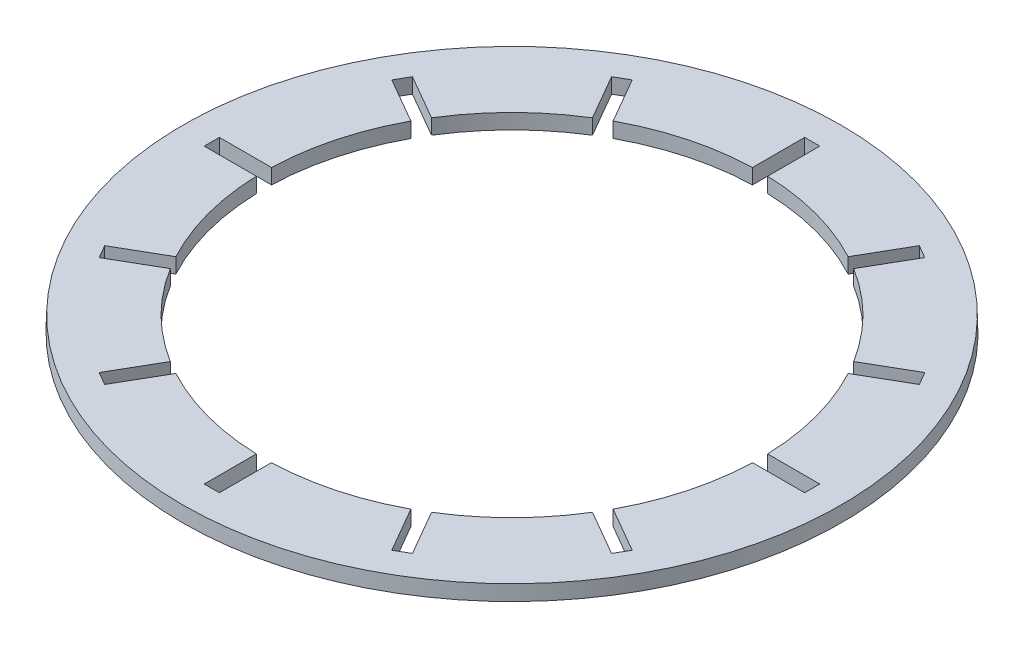
from build123d import *

# Parameters (mm, degrees)
SKETCH1_R           = 108.978645108
SKETCH1_R_2         = 82.075459911
BOSS_EXTRUDE1_DEPTH = 5
SKETCH3_W           = 27.601566605
SKETCH3_H           = 5
CUT_EXTRUDE1_DEPTH  = 5
CIRPATTERN1_COUNT   = 12


with BuildPart() as part:
    # Sketch1 → Boss-Extrude1 (new body)
    with BuildSketch(Plane(origin=(0, 0, 0), x_dir=(1, 0, 0), z_dir=(0, 1, 0))):
        Circle(SKETCH1_R)
        Circle(SKETCH1_R_2, mode=Mode.SUBTRACT)
    extrude(amount=BOSS_EXTRUDE1_DEPTH)

    # Sketch2 → Cut-Revolve1 (revolve, cut)
    with BuildSketch(Plane.XY):
        Polygon((108.978645108, 0), (108.468178891, 15.211545536), (125.564128825, 15.211545536), (125.564128825, 0), align=None)
    revolve(axis=Axis((0, 0, 0), (0, 1, 0)), mode=Mode.SUBTRACT)

    # Sketch3 → Cut-Extrude1 (cut)
    with BuildSketch(Plane(origin=(0, 5, 0), x_dir=(1, 0, 0), z_dir=(0, 1, 0))):
        with Locations((85.467576893, 0)):
            Rectangle(SKETCH3_W, SKETCH3_H)
    cut_extrude1 = extrude(amount=-CUT_EXTRUDE1_DEPTH, mode=Mode.SUBTRACT)

    # CirPattern1: Cut-Extrude1 ×12 about axis
    cirpattern1_axis = Axis((0, 0, 0), (0, 1, 0))
    for i in range(1, CIRPATTERN1_COUNT):
        add(cut_extrude1.rotate(cirpattern1_axis, i * 360 / CIRPATTERN1_COUNT), mode=Mode.SUBTRACT)


solid = part.part
